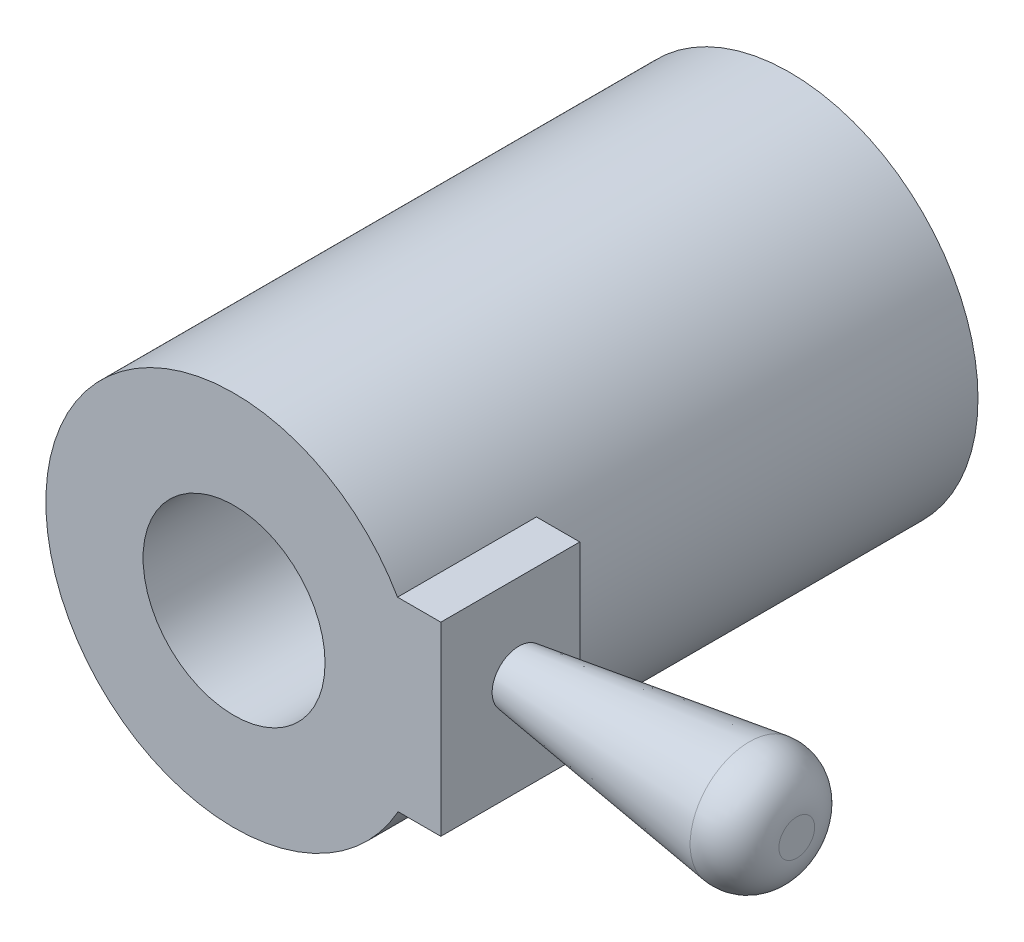
from build123d import *

# Parameters (mm, degrees)
SKETCH2_R           = 34.410626859
SKETCH2_R_2         = 16.637
BOSS_EXTRUDE1_DEPTH = 101.6
SKETCH3_W           = 16.158329911
SKETCH3_H           = 33.912544257
BOSS_EXTRUDE2_DEPTH = 25.4
SKETCH4_R           = 4.896317789
BOSS_EXTRUDE3_DEPTH = 50.8
BOSS_EXTRUDE3_TAPER = -8
FILLET1_R           = 7.62


with BuildPart() as part:
    # Sketch2 → Boss-Extrude1 (new body)
    with BuildSketch(Plane.XY):
        Circle(SKETCH2_R)
        Circle(SKETCH2_R_2, mode=Mode.SUBTRACT)
    extrude(amount=BOSS_EXTRUDE1_DEPTH)

    # Sketch3 → Boss-Extrude2 (add)
    with BuildSketch(Plane.XY.offset(101.6)):
        with Locations((29.723347614, 0.099742777)):
            Rectangle(SKETCH3_W, SKETCH3_H)
    extrude(amount=-BOSS_EXTRUDE2_DEPTH)

    # Sketch4 → Boss-Extrude3 (add)
    with BuildSketch(Plane(origin=(37.802512569, 0, 0), x_dir=(0, 0, -1), z_dir=(1, 0, 0))):
        with Locations((-87.324916431, 1.22659491)):
            Circle(SKETCH4_R)
    extrude(amount=BOSS_EXTRUDE3_DEPTH, taper=BOSS_EXTRUDE3_TAPER)

    # Fillet1
    fillet1_edges = [part.edges().sort_by_distance(p)[0] for p in [
        (88.602512569, 1.22659491, 99.360708623),
    ]]
    fillet(fillet1_edges, radius=FILLET1_R)


solid = part.part
